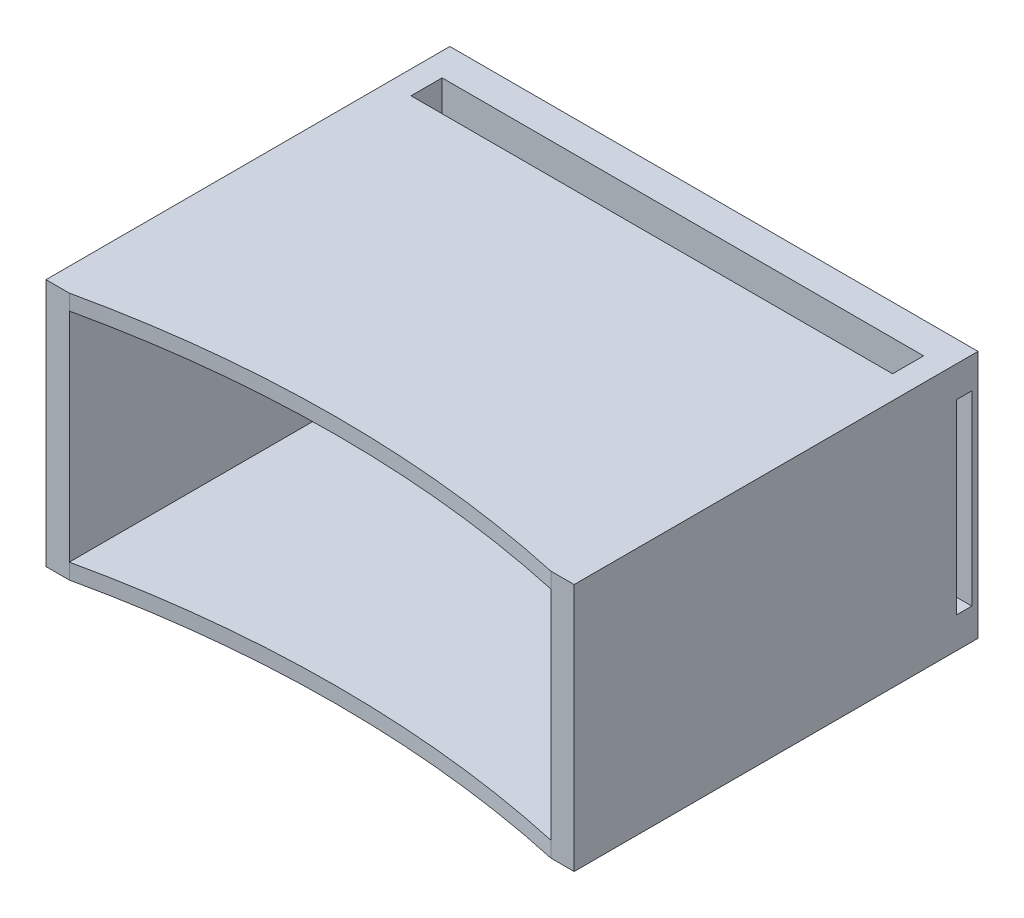
from build123d import *

# Parameters (mm, degrees)
SKETCH1_W            = 170
SKETCH1_H            = 90
BOSS_EXTRUDE1_DEPTH  = 80
SKETCH3_W            = 170
SKETCH3_H            = 80
BOSS_EXTRUDE3_DEPTH  = 30
SKETCH5_W            = 155
SKETCH5_H            = 70
CUT_EXTRUDE3_DEPTH   = 110
SKETCH4_W            = 155
SKETCH4_H            = 10
CUT_EXTRUDE4_DEPTH   = 75
SKETCH6_W            = 1.5
SKETCH6_H            = 35
BOSS_EXTRUDE9_DEPTH  = 15
SKETCH7_W            = 152
SKETCH7_H            = 3.5
BOSS_EXTRUDE10_DEPTH = 5
SKETCH10_W           = 170
SKETCH10_H           = 80
SKETCH10_W_2         = 155
SKETCH10_H_2         = 70
BOSS_EXTRUDE13_DEPTH = 10
CUT_EXTRUDE5_DEPTH   = 81
SKETCH14_W           = 5
SKETCH14_H           = 60
CUT_EXTRUDE6_DEPTH   = 171


with BuildPart() as part:
    # Sketch1 → Boss-Extrude1 (new body)
    with BuildSketch(Plane(origin=(0, 0, 0), x_dir=(1, 0, 0), z_dir=(0, 1, 0))):
        Rectangle(SKETCH1_W, SKETCH1_H)
    extrude(amount=BOSS_EXTRUDE1_DEPTH)

    # Sketch3 → Boss-Extrude3 (add)
    with BuildSketch(Plane.XY.offset(45)):
        with Locations((0, 40)):
            Rectangle(SKETCH3_W, SKETCH3_H)
    extrude(amount=BOSS_EXTRUDE3_DEPTH)

    # Sketch5 → Cut-Extrude3 (cut)
    with BuildSketch(Plane.XY.offset(75)):
        with Locations((0, 40)):
            Rectangle(SKETCH5_W, SKETCH5_H)
    extrude(amount=-CUT_EXTRUDE3_DEPTH, mode=Mode.SUBTRACT)

    # Sketch4 → Cut-Extrude4 (cut)
    with BuildSketch(Plane(origin=(0, 80, 0), x_dir=(1, 0, 0), z_dir=(0, 1, 0))):
        with Locations((0, 30)):
            Rectangle(SKETCH4_W, SKETCH4_H)
    extrude(amount=-CUT_EXTRUDE4_DEPTH, mode=Mode.SUBTRACT)

    # Sketch6 → Boss-Extrude9 (add)
    with BuildSketch(Plane.XY.offset(-35)):
        with Locations((76.75, 22.5)):
            Rectangle(SKETCH6_W, SKETCH6_H)
        with Locations((-76.75, 22.5)):
            Rectangle(SKETCH6_W, SKETCH6_H)
    extrude(amount=BOSS_EXTRUDE9_DEPTH)

    # Sketch7 → Boss-Extrude10 (add)
    with BuildSketch(Plane(origin=(0, 5, 0), x_dir=(1, 0, 0), z_dir=(0, 1, 0))):
        with Locations((0, 21.25)):
            Rectangle(SKETCH7_W, SKETCH7_H)
    extrude(amount=BOSS_EXTRUDE10_DEPTH)

    # Sketch10 → Boss-Extrude13 (add)
    with BuildSketch(Plane.XY.offset(75)):
        with Locations((0, 40)):
            Rectangle(SKETCH10_W, SKETCH10_H)
        with Locations((0, 40)):
            Rectangle(SKETCH10_W_2, SKETCH10_H_2, mode=Mode.SUBTRACT)
    extrude(amount=BOSS_EXTRUDE13_DEPTH)

    # Sketch11 → Cut-Extrude5 (cut, through all)
    with BuildSketch(Plane(origin=(0, 80, 0), x_dir=(1, 0, 0), z_dir=(0, 1, 0))):
        with BuildLine():
            Line((77.5, -85), (-77.5, -85))
            ThreePointArc((-77.5, -85), (0, -76.559027761), (77.5, -85))
        make_face()
    extrude(amount=-CUT_EXTRUDE5_DEPTH, mode=Mode.SUBTRACT)

    # Sketch14 → Cut-Extrude6 (cut, through all)
    with BuildSketch(Plane(origin=(85, 0, 0), x_dir=(0, 0, -1), z_dir=(1, 0, 0))):
        with Locations((40.5, 40)):
            Rectangle(SKETCH14_W, SKETCH14_H)
    extrude(amount=-CUT_EXTRUDE6_DEPTH, mode=Mode.SUBTRACT)


solid = part.part
